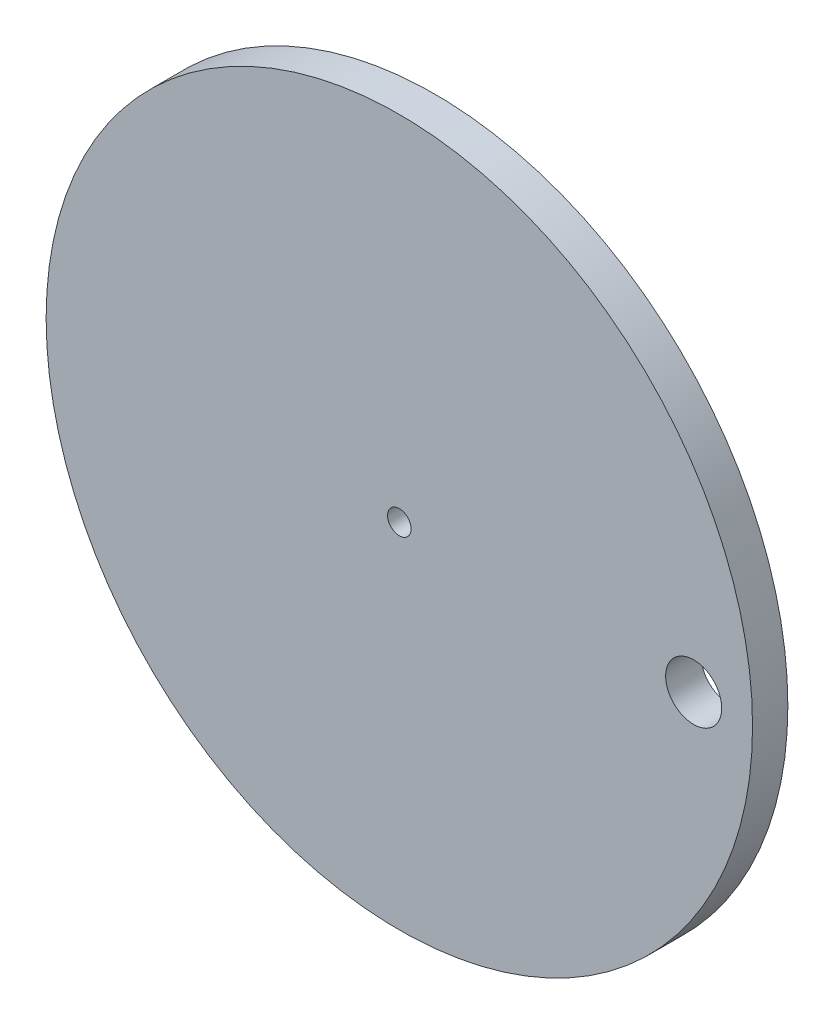
from build123d import *

# Parameters (mm, degrees)
CROQUIS1_R              = 30
CROQUIS1_R_2            = 1
CROQUIS1_R_3            = 2.38125
SALIENTE_EXTRUIR1_DEPTH = 3


with BuildPart() as part:
    # Croquis1 → Saliente-Extruir1 (new body)
    with BuildSketch(Plane.XY):
        Circle(CROQUIS1_R)
        Circle(CROQUIS1_R_2, mode=Mode.SUBTRACT)
        with Locations((25, 0)):
            Circle(CROQUIS1_R_3, mode=Mode.SUBTRACT)
    extrude(amount=SALIENTE_EXTRUIR1_DEPTH)


solid = part.part
